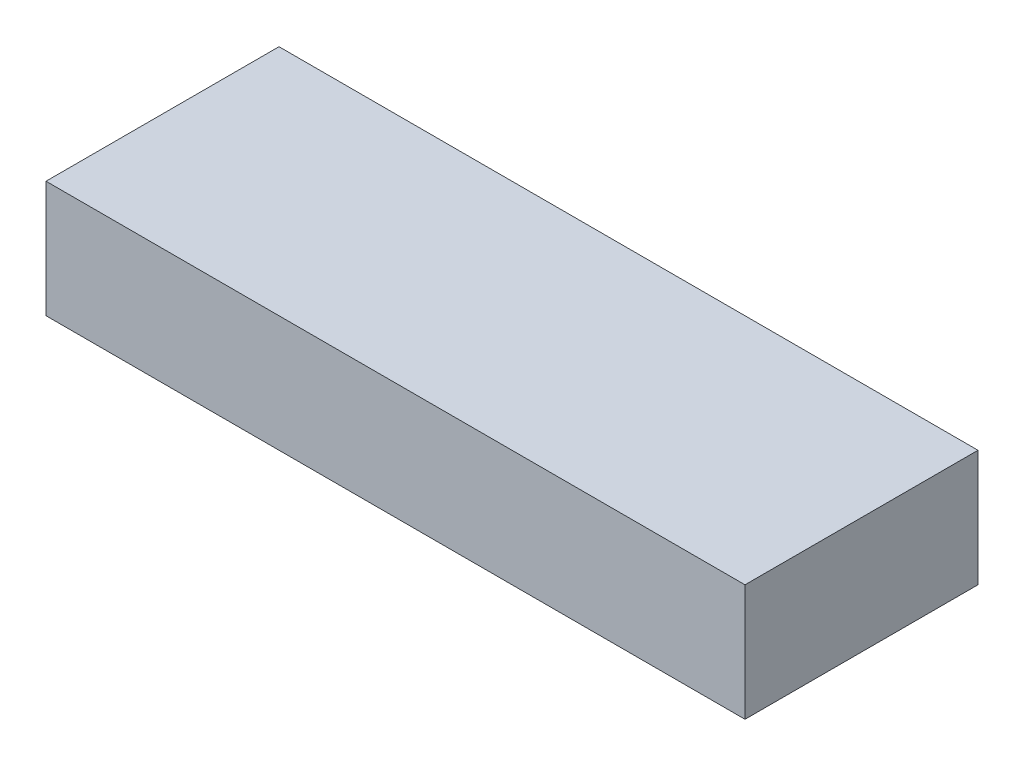
from build123d import *

# Parameters (mm, degrees)
SKETCH1_W           = 30
SKETCH1_H           = 10
BOSS_EXTRUDE1_DEPTH = 5


with BuildPart() as part:
    # Sketch1 → Boss-Extrude1 (new body)
    with BuildSketch(Plane(origin=(0, 0, 0), x_dir=(1, 0, 0), z_dir=(0, 1, 0))):
        with Locations((15, 5)):
            Rectangle(SKETCH1_W, SKETCH1_H)
    extrude(amount=BOSS_EXTRUDE1_DEPTH)


solid = part.part
